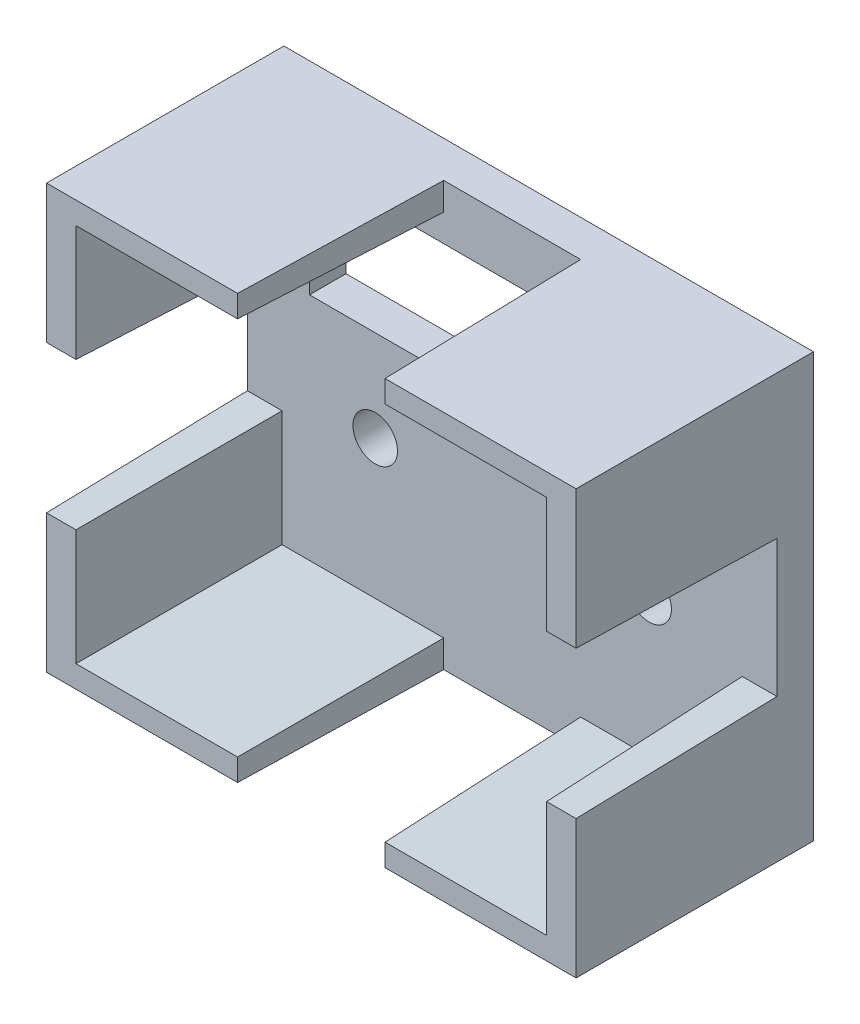
from build123d import *

# Parameters (mm, degrees)
SKETCH2_W           = 36.83
SKETCH2_H           = 29.464
SKETCH2_R           = 1.55
SKETCH2_W_2         = 28.194
SKETCH2_H_2         = 7.747
BOSS_EXTRUDE1_DEPTH = 16.51
CUT_EXTRUDE1_START  = 2.54
SKETCH2_5_W         = 32.004
SKETCH2_5_H         = 25.654
SKETCH2_5_R         = 1.55
SKETCH2_5_W_2       = 28.194
SKETCH2_5_H_2       = 7.747
SKETCH2_5_W_3       = 2.413
SKETCH2_5_H_3       = 9.525
SKETCH2_5_W_4       = 9.525
SKETCH2_5_H_4       = 1.905
CUT_EXTRUDE1_DEPTH  = 14.97
CUT_EXTRUDE1_TAPER  = -1.5


with BuildPart() as part:
    # Sketch2 → Boss-Extrude1 (new body)
    with BuildSketch(Plane.XY):
        Rectangle(SKETCH2_W, SKETCH2_H)
        with Locations((-9.525, -3.175)):
            Circle(SKETCH2_R, mode=Mode.SUBTRACT)
        with Locations((9.525, -3.175)):
            Circle(SKETCH2_R, mode=Mode.SUBTRACT)
        with Locations((0, 7.0485)):
            Rectangle(SKETCH2_W_2, SKETCH2_H_2, mode=Mode.SUBTRACT)
    extrude(amount=BOSS_EXTRUDE1_DEPTH)

    # Sketch2_5 → Cut-Extrude1 (cut, through all)
    with BuildSketch(Plane.XY.offset(CUT_EXTRUDE1_START)):
        Rectangle(SKETCH2_5_W, SKETCH2_5_H)
        with Locations((9.525, -3.175)):
            Circle(SKETCH2_5_R, mode=Mode.SUBTRACT)
        with Locations((-9.525, -3.175)):
            Circle(SKETCH2_5_R, mode=Mode.SUBTRACT)
        with Locations((0, 7.0485)):
            Rectangle(SKETCH2_5_W_2, SKETCH2_5_H_2, mode=Mode.SUBTRACT)
        with Locations((17.2085, 0)):
            Rectangle(SKETCH2_5_W_3, SKETCH2_5_H_3)
        with Locations((0, -13.7795)):
            Rectangle(SKETCH2_5_W_4, SKETCH2_5_H_4)
        with Locations((-17.2085, 0)):
            Rectangle(SKETCH2_5_W_3, SKETCH2_5_H_3)
        with Locations((0, 13.7795)):
            Rectangle(SKETCH2_5_W_4, SKETCH2_5_H_4)
    extrude(amount=CUT_EXTRUDE1_DEPTH, taper=CUT_EXTRUDE1_TAPER, mode=Mode.SUBTRACT)


solid = part.part
